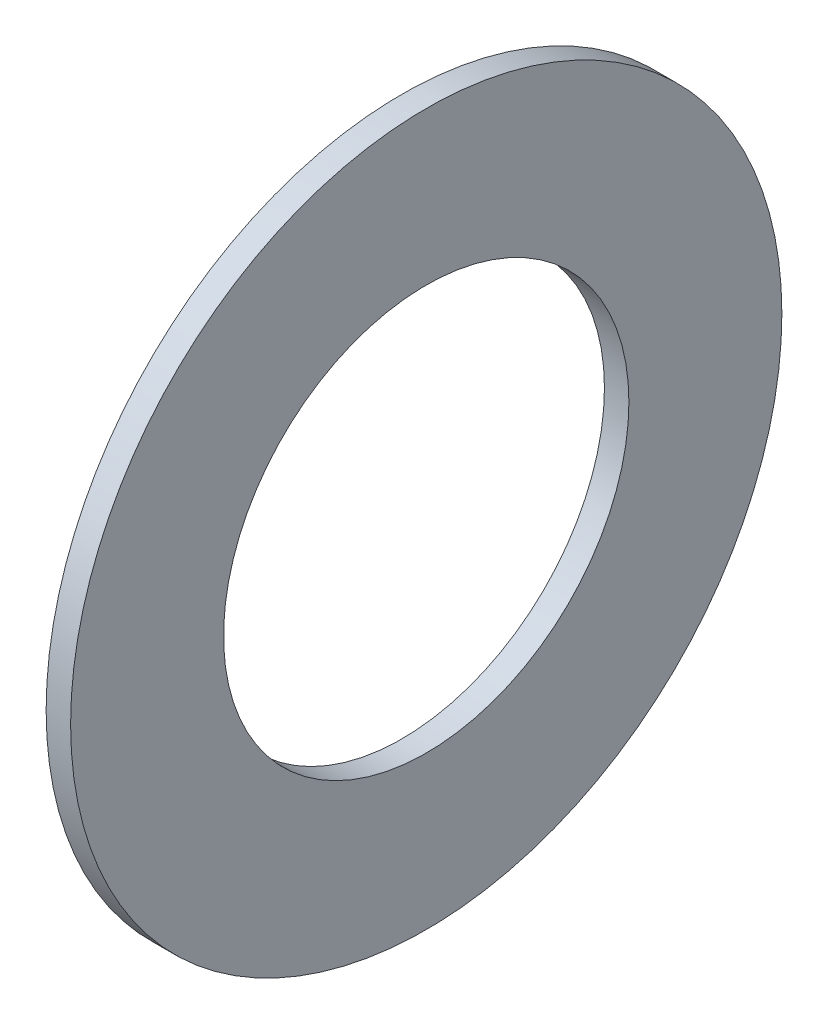
from build123d import *

# Parameters (mm, degrees)
SKETCH1_R      = 11.811
SKETCH1_R_2    = 6.731
EXTRUDE1_DEPTH = 0.8128


with BuildPart() as part:
    # Sketch1 → Extrude1 (new body)
    with BuildSketch(Plane(origin=(0, 0, 0), x_dir=(0, 0, -1), z_dir=(1, 0, 0))):
        Circle(SKETCH1_R)
        Circle(SKETCH1_R_2, mode=Mode.SUBTRACT)
    extrude(amount=EXTRUDE1_DEPTH)


solid = part.part
